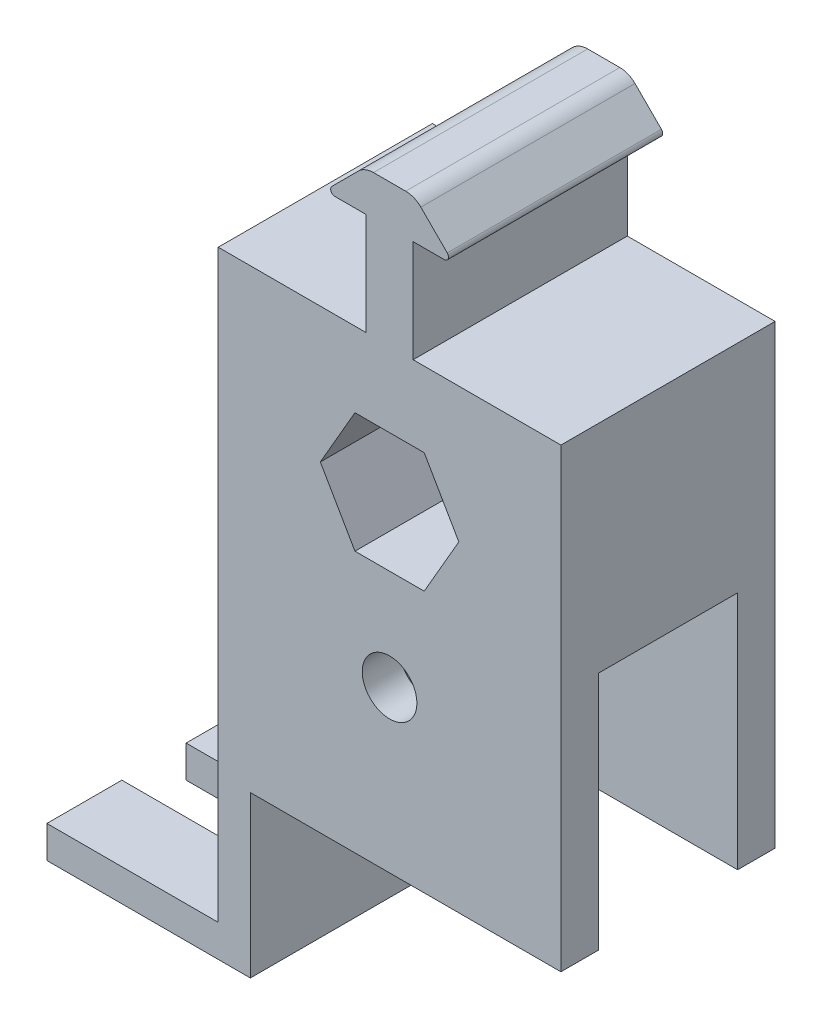
from build123d import *

# Parameters (mm, degrees)
BOSS_EXTRUDE1_DEPTH             = 12.7
BOSS_EXTRUDE4_REACH             = 14.7
BOSS_EXTRUDE4_DIRECTION_2_REACH = 14.7
SKETCH6_W                       = 16.51
SKETCH6_H                       = 15.748
CUT_EXTRUDE2_DEPTH              = 61.96
SKETCH11_W                      = 20.32
SKETCH11_H                      = 7.62
CUT_EXTRUDE3_DEPTH              = 3.81
SKETCH15_R                      = 3.2385
CUT_EXTRUDE4_DEPTH              = 25.4
SKETCH16_W                      = 16.51
SKETCH16_H                      = 12.7
CUT_EXTRUDE5_DEPTH              = 36.83


with BuildPart() as part:
    # Sketch1 → Boss-Extrude1 (new body, symmetric)
    with BuildSketch(Plane.XY):
        with BuildLine():
            Line((-20.32, 16.002), (-20.32, -38.1))
            Line((-20.32, -38.1), (20.32, -38.1))
            Line((20.32, -38.1), (20.32, 16.002))
            Line((20.32, 16.002), (2.794, 16.002))
            Line((2.794, 16.002), (2.794, 28.1305))
            Line((2.794, 28.1305), (6.477, 28.1305))
            ThreePointArc((6.477, 28.1305), (6.946330803, 28.444096816), (6.836210245, 28.997710245))
            Line((6.836210245, 28.997710245), (3.706459265, 32.127461224))
            ThreePointArc((3.706459265, 32.127461224), (2.882423959, 32.678064013), (1.910408041, 32.87141))
            Line((1.910408041, 32.87141), (-1.910408041, 32.87141))
            ThreePointArc((-1.910408041, 32.87141), (-2.882423959, 32.678064013), (-3.706459265, 32.127461224))
            Line((-3.706459265, 32.127461224), (-6.836210245, 28.997710245))
            ThreePointArc((-6.836210245, 28.997710245), (-6.946330803, 28.444096816), (-6.477, 28.1305))
            Line((-6.477, 28.1305), (-2.794, 28.1305))
            Line((-2.794, 28.1305), (-2.794, 16.002))
            Line((-2.794, 16.002), (-20.32, 16.002))
        make_face()
        Polygon((-4.106115114, 7.112), (-8.212230229, 0), (-4.106115114, -7.112), (4.106115114, -7.112), (8.212230229, 0), (4.106115114, 7.112), align=None, mode=Mode.SUBTRACT)
    extrude(amount=BOSS_EXTRUDE1_DEPTH, both=True)

    # Boss-Extrude4: up to this face of the body (flat: up to its plane)
    boss_extrude4_end = Plane(part.part.faces().sort_by_distance((0, -9.949298675, 12.7))[0])
    # Sketch10 → Boss-Extrude4 (add, up to the picked face)
    with BuildSketch(Plane.XY, mode=Mode.PRIVATE) as boss_extrude4_sk1:
        Polygon((-20.32, -38.1), (-20.32, -53.34), (-40.64, -53.34), (-40.64, -57.15), (-16.51, -57.15), (-16.51, -38.1), align=None)
    boss_extrude4_tool1 = split(extrude(boss_extrude4_sk1.sketch, amount=BOSS_EXTRUDE4_REACH, mode=Mode.PRIVATE), bisect_by=boss_extrude4_end, keep=Keep.BOTH, mode=Mode.PRIVATE)
    add(boss_extrude4_tool1.solids().sort_by_distance((-20.012566, -45.72, 0))[0])

    # Boss-Extrude4 direction 2: up to this face of the body (flat: up to its plane)
    boss_extrude4_direction_2_end = Plane(part.part.faces().sort_by_distance((0, -9.949298675, -12.7))[0])
    # Sketch10 → Boss-Extrude4 direction 2 (add, up to the picked face)
    with BuildSketch(Plane.XY, mode=Mode.PRIVATE) as boss_extrude4_direction_2_sk1:
        Polygon((-20.32, -38.1), (-20.32, -53.34), (-40.64, -53.34), (-40.64, -57.15), (-16.51, -57.15), (-16.51, -38.1), align=None)
    boss_extrude4_direction_2_tool1 = split(extrude(boss_extrude4_direction_2_sk1.sketch, amount=-BOSS_EXTRUDE4_DIRECTION_2_REACH, mode=Mode.PRIVATE), bisect_by=boss_extrude4_direction_2_end, keep=Keep.BOTH, mode=Mode.PRIVATE)
    add(boss_extrude4_direction_2_tool1.solids().sort_by_distance((-20.012566, -45.72, 0))[0])

    # Sketch6 → Cut-Extrude2 (cut, through all)
    with BuildSketch(Plane(origin=(20.32, 0, 0), x_dir=(0, 0, -1), z_dir=(1, 0, 0))):
        with Locations((0, -17.526)):
            Rectangle(SKETCH6_W, SKETCH6_H)
    extrude(amount=-CUT_EXTRUDE2_DEPTH, mode=Mode.SUBTRACT)

    # Sketch11 → Cut-Extrude3 (cut)
    with BuildSketch(Plane(origin=(0, -53.34, 0), x_dir=(1, 0, 0), z_dir=(0, 1, 0))):
        with Locations((-30.48, 0)):
            Rectangle(SKETCH11_W, SKETCH11_H)
    extrude(amount=-CUT_EXTRUDE3_DEPTH, mode=Mode.SUBTRACT)

    # Sketch15 → Cut-Extrude4 (cut)
    with BuildSketch(Plane.XY.offset(12.7)):
        with Locations((0, -19.05)):
            Circle(SKETCH15_R)
    extrude(amount=-CUT_EXTRUDE4_DEPTH, mode=Mode.SUBTRACT)

    # Sketch16 → Cut-Extrude5 (cut)
    with BuildSketch(Plane(origin=(20.32, 0, 0), x_dir=(0, 0, -1), z_dir=(1, 0, 0))):
        with Locations((0, -31.75)):
            Rectangle(SKETCH16_W, SKETCH16_H)
    extrude(amount=-CUT_EXTRUDE5_DEPTH, mode=Mode.SUBTRACT)


solid = part.part
